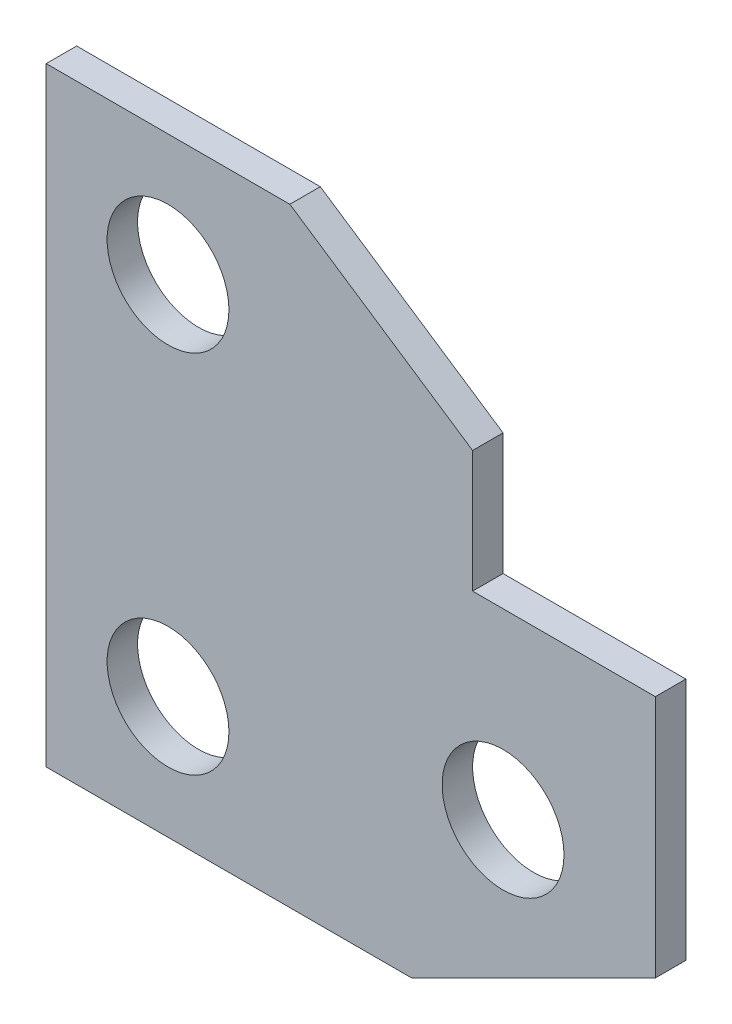
from build123d import *

# Parameters (mm, degrees)
SKETCH1_R           = 10
BOSS_EXTRUDE1_DEPTH = 5


with BuildPart() as part:
    # Sketch1 → Boss-Extrude1 (new body)
    with BuildSketch(Plane.XY):
        Polygon((-73.294117647, 93.764705882), (-73.294117647, -6.235294118), (-13.294117647, -6.235294118), (26.705882353, 13.764705882), (26.705882353, 53.764705882), (-3.294117647, 53.764705882), (-3.294117647, 73.764705882), (-33.294117647, 93.764705882), align=None)
        with Locations((-53.294117647, 73.764705882)):
            Circle(SKETCH1_R, mode=Mode.SUBTRACT)
        with Locations((-53.294117647, 13.764705882)):
            Circle(SKETCH1_R, mode=Mode.SUBTRACT)
        with Locations((1.705882353, 23.764705882)):
            Circle(SKETCH1_R, mode=Mode.SUBTRACT)
    extrude(amount=BOSS_EXTRUDE1_DEPTH)


solid = part.part
